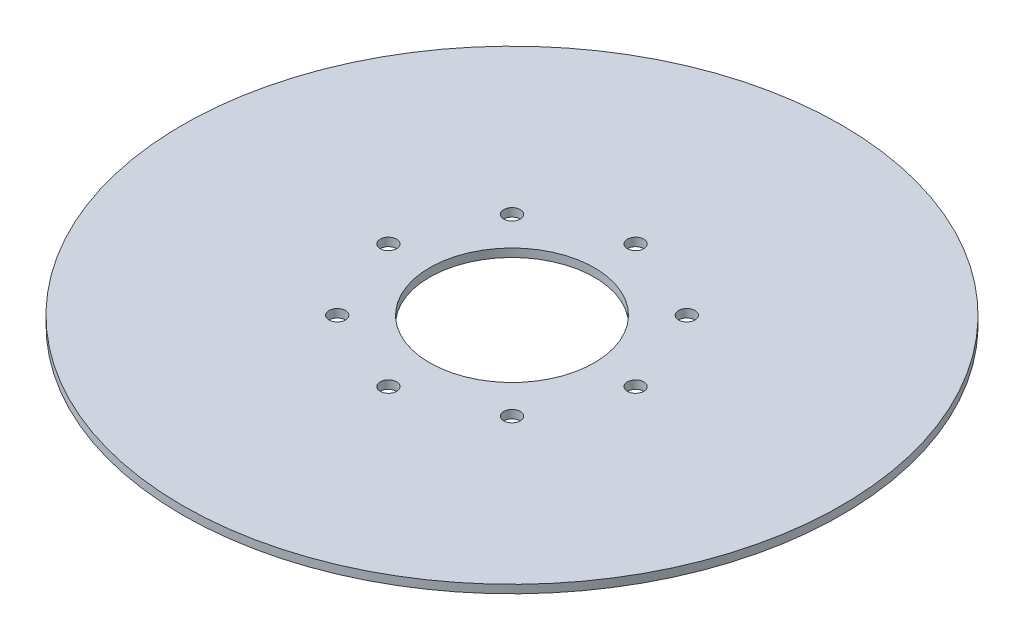
from build123d import *

# Parameters (mm, degrees)
SKETCH2_R           = 40
BOSS_EXTRUDE1_DEPTH = 1
SKETCH3_R           = 10
CUT_EXTRUDE1_DEPTH  = 2
SKETCH4_R           = 1
CUT_EXTRUDE2_DEPTH  = 2


with BuildPart() as part:
    # Sketch2 → Boss-Extrude1 (new body)
    with BuildSketch(Plane(origin=(0, 0, 0), x_dir=(1, 0, 0), z_dir=(0, 1, 0))):
        Circle(SKETCH2_R)
    extrude(amount=BOSS_EXTRUDE1_DEPTH)

    # Sketch3 → Cut-Extrude1 (cut, through all)
    with BuildSketch(Plane(origin=(0, 1, 0), x_dir=(1, 0, 0), z_dir=(0, 1, 0))):
        Circle(SKETCH3_R)
    extrude(amount=-CUT_EXTRUDE1_DEPTH, mode=Mode.SUBTRACT)

    # Sketch4 → Cut-Extrude2 (cut, through all)
    with BuildSketch(Plane(origin=(0, 1, 0), x_dir=(1, 0, 0), z_dir=(0, 1, 0))):
        with Locations((0, 15)):
            Circle(SKETCH4_R)
        with Locations((10.606601718, 10.606601718)):
            Circle(SKETCH4_R)
        with Locations((15, 0)):
            Circle(SKETCH4_R)
        with Locations((10.606601718, -10.606601718)):
            Circle(SKETCH4_R)
        with Locations((0, -15)):
            Circle(SKETCH4_R)
        with Locations((-10.606601718, -10.606601718)):
            Circle(SKETCH4_R)
        with Locations((-15, 0)):
            Circle(SKETCH4_R)
        with Locations((-10.606601718, 10.606601718)):
            Circle(SKETCH4_R)
    extrude(amount=-CUT_EXTRUDE2_DEPTH, mode=Mode.SUBTRACT)


solid = part.part
